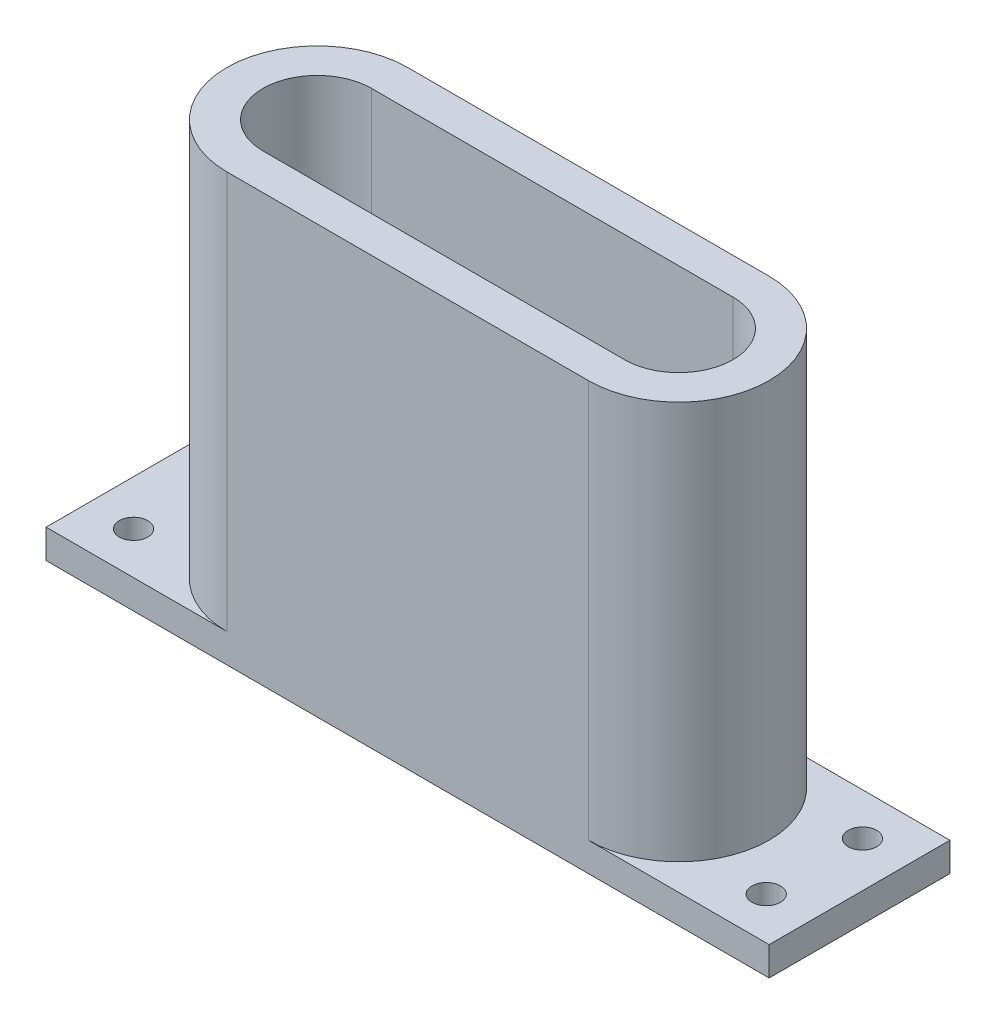
from build123d import *

# Parameters (mm, degrees)
BOSS_EXTRUDE1_DEPTH = 60
SKETCH2_W           = 101.6
SKETCH2_H           = 25.4
SKETCH2_R           = 2
BOSS_EXTRUDE2_DEPTH = 4.064


with BuildPart() as part:
    # Sketch1 → Boss-Extrude1 (new body)
    with BuildSketch(Plane(origin=(0, 0, 0), x_dir=(1, 0, 0), z_dir=(0, 1, 0))):
        with BuildLine():
            Line((-25.4, -12.7), (25.4, -12.7))
            ThreePointArc((25.4, -12.7), (38.1, 0), (25.4, 12.7))
            Line((25.4, 12.7), (-25.4, 12.7))
            ThreePointArc((-25.4, 12.7), (-38.1, 0), (-25.4, -12.7))
        make_face()
        with BuildLine():
            Line((-25.4, -7.62), (25.4, -7.62))
            ThreePointArc((25.4, -7.62), (33.02, 0), (25.4, 7.62))
            Line((25.4, 7.62), (-25.4, 7.62))
            ThreePointArc((-25.4, 7.62), (-33.02, 0), (-25.4, -7.62))
        make_face(mode=Mode.SUBTRACT)
    extrude(amount=BOSS_EXTRUDE1_DEPTH)

    # Sketch2 → Boss-Extrude2 (add)
    with BuildSketch(Plane.XZ):
        Rectangle(SKETCH2_W, SKETCH2_H)
        with Locations((-44.45, -6.762856744)):
            Circle(SKETCH2_R, mode=Mode.SUBTRACT)
        with Locations((-44.45, 6.762856744)):
            Circle(SKETCH2_R, mode=Mode.SUBTRACT)
        with Locations((44.45, 6.762856744)):
            Circle(SKETCH2_R, mode=Mode.SUBTRACT)
        with Locations((44.45, -6.762856744)):
            Circle(SKETCH2_R, mode=Mode.SUBTRACT)
        with BuildLine():
            Line((-25.4, -7.62), (25.4, -7.62))
            ThreePointArc((25.4, -7.62), (33.02, 0), (25.4, 7.62))
            Line((25.4, 7.62), (-25.4, 7.62))
            ThreePointArc((-25.4, 7.62), (-33.02, 0), (-25.4, -7.62))
        make_face(mode=Mode.SUBTRACT)
    extrude(amount=-BOSS_EXTRUDE2_DEPTH)


solid = part.part
